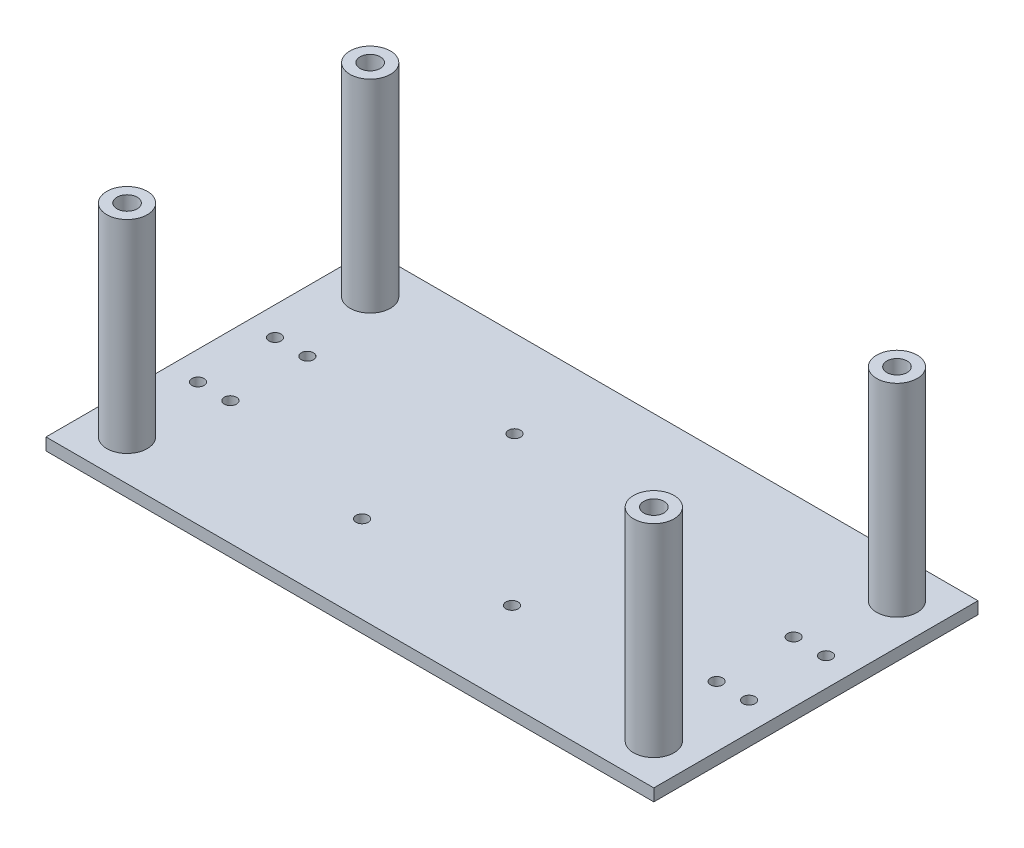
from build123d import *

# Parameters (mm, degrees)
SKETCH2_W           = 150
SKETCH2_H           = 80
SKETCH2_R           = 1.5
BOSS_EXTRUDE1_DEPTH = 3
SKETCH3_R           = 5
SKETCH3_R_2         = 2.5
BOSS_EXTRUDE2_DEPTH = 50
SKETCH4_R           = 1.5
CUT_EXTRUDE1_DEPTH  = 10


with BuildPart() as part:
    # Sketch2 → Boss-Extrude1 (new body)
    with BuildSketch(Plane(origin=(0, 0, 0), x_dir=(1, 0, 0), z_dir=(0, 1, 0))):
        with Locations((-8.46473029, 1.825726141)):
            Rectangle(SKETCH2_W, SKETCH2_H)
        with Locations((-68.46473029, 11.325726141)):
            Circle(SKETCH2_R, mode=Mode.SUBTRACT)
        with Locations((-68.46473029, -7.674273859)):
            Circle(SKETCH2_R, mode=Mode.SUBTRACT)
        with Locations((-76.46473029, 11.325726141)):
            Circle(SKETCH2_R, mode=Mode.SUBTRACT)
        with Locations((-76.46473029, -7.674273859)):
            Circle(SKETCH2_R, mode=Mode.SUBTRACT)
        with Locations((51.53526971, -7.674273859)):
            Circle(SKETCH2_R, mode=Mode.SUBTRACT)
        with Locations((59.53526971, -7.674273859)):
            Circle(SKETCH2_R, mode=Mode.SUBTRACT)
        with Locations((59.53526971, 11.325726141)):
            Circle(SKETCH2_R, mode=Mode.SUBTRACT)
        with Locations((51.53526971, 11.325726141)):
            Circle(SKETCH2_R, mode=Mode.SUBTRACT)
    extrude(amount=-BOSS_EXTRUDE1_DEPTH)

    # Sketch3 → Boss-Extrude2 (add)
    with BuildSketch(Plane(origin=(0, 0, 0), x_dir=(1, 0, 0), z_dir=(0, 1, 0))):
        with Locations((-73.46473029, 31.825726141)):
            Circle(SKETCH3_R)
        with Locations((-73.46473029, 31.825726141)):
            Circle(SKETCH3_R_2, mode=Mode.SUBTRACT)
        with Locations((56.53526971, 31.825726141)):
            Circle(SKETCH3_R)
        with Locations((56.53526971, 31.825726141)):
            Circle(SKETCH3_R_2, mode=Mode.SUBTRACT)
        with Locations((56.53526971, -28.174273859)):
            Circle(SKETCH3_R)
        with Locations((56.53526971, -28.174273859)):
            Circle(SKETCH3_R_2, mode=Mode.SUBTRACT)
        with Locations((-73.46473029, -28.174273859)):
            Circle(SKETCH3_R)
        with Locations((-73.46473029, -28.174273859)):
            Circle(SKETCH3_R_2, mode=Mode.SUBTRACT)
    extrude(amount=BOSS_EXTRUDE2_DEPTH)

    # Sketch4 → Cut-Extrude1 (cut)
    with BuildSketch(Plane.XZ.offset(3)):
        with Locations((-26.96473029, 16.674273859)):
            Circle(SKETCH4_R)
        with Locations((10.03526971, 16.674273859)):
            Circle(SKETCH4_R)
        with Locations((10.03526971, -20.325726141)):
            Circle(SKETCH4_R)
        with Locations((-26.353154243, -20.325726141)):
            Circle(SKETCH4_R)
    extrude(amount=-CUT_EXTRUDE1_DEPTH, mode=Mode.SUBTRACT)


solid = part.part
